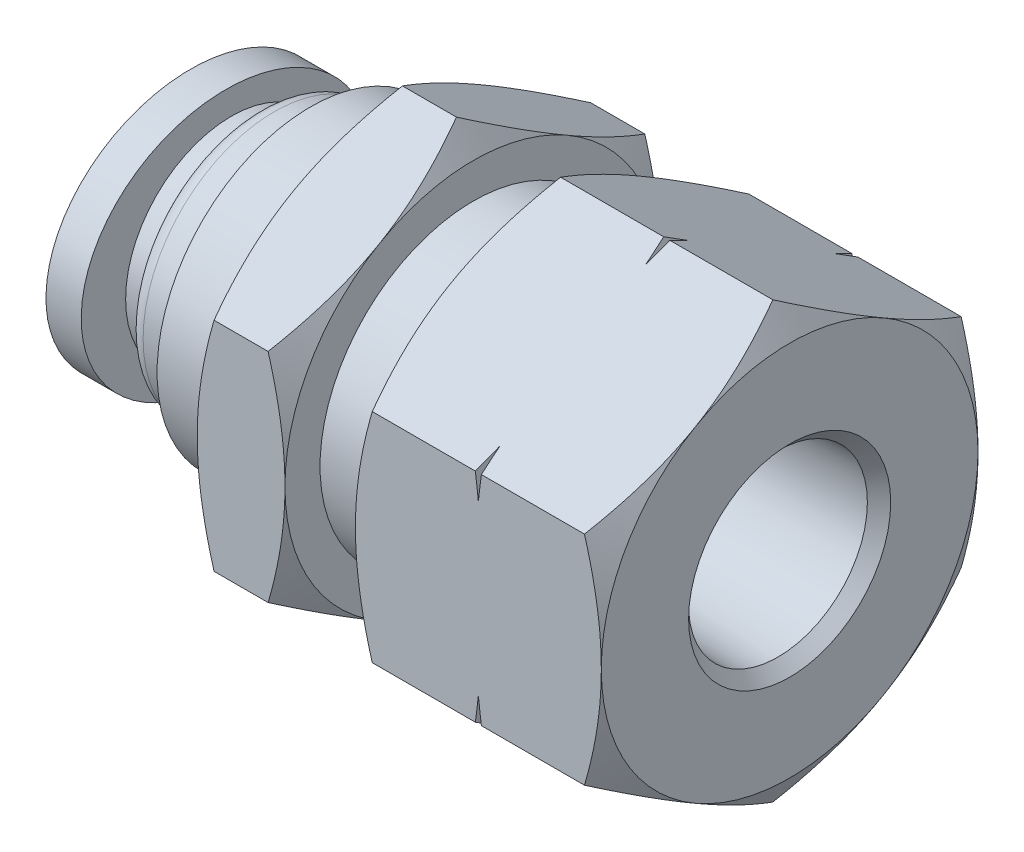
from build123d import *

# Parameters (mm, degrees)
BOSS_EXTRUDE1_DEPTH = 13.49375
CHAMFER1_SIZE2      = 0.508
CHAMFER1_SIZE       = 0.525425432
SKETCH3_RX          = 6.50875
SKETCH3_RY          = 5.6769
SKETCH3_R           = 3.3147
BOSS_EXTRUDE2_DEPTH = 1.5875


with BuildPart() as part:
    # Sketch1 → Boss-Extrude1 (new body, symmetric)
    with BuildSketch(Plane(origin=(0, 0, 0), x_dir=(0, 0, -1), z_dir=(1, 0, 0))):
        Polygon((0, 9.796017487), (-8.4836, 4.898008744), (-8.4836, -4.898008744), (0, -9.796017487), (8.4836, -4.898008744), (8.4836, 4.898008744), align=None)
    extrude(amount=BOSS_EXTRUDE1_DEPTH, both=True)

    # Sketch2 → Cut-Revolve1 (revolve, cut)
    with BuildSketch(Plane.XY):
        Polygon((13.49375, 9.796017487), (13.49375, 8.4836), (12.73602541, 9.796017487), align=None)
        Polygon((3.17707459, 9.796017487), (-1.51337459, 9.796017487), (-0.75565, 8.4836), (-0.75565, 6.90245), (2.41935, 6.90245), (2.41935, 8.4836), align=None)
        Polygon((7.82043181, 9.796017487), (7.95655, 9.288017487), (8.09266819, 9.796017487), align=None)
        with BuildLine():
            Line((-3.94762541, 9.796017487), (-4.70535, 8.4836))
            Line((-4.70535, 8.4836), (-4.70535, 6.90245))
            Line((-4.70535, 6.90245), (-8.09625, 6.90245))
            Line((-8.09625, 6.90245), (-8.09625, 5.9055))
            Line((-8.09625, 5.9055), (-9.72185, 5.9055))
            ThreePointArc((-9.72185, 5.9055), (-10.260665367, 5.682315367), (-10.48385, 5.1435))
            Line((-10.48385, 5.1435), (-10.48385, 4.7625))
            Line((-10.48385, 4.7625), (-11.65225, 4.7625))
            Line((-11.65225, 4.7625), (-11.65225, 3.81))
            Line((-11.65225, 3.81), (-13.49375, 3.81))
            Line((-13.49375, 3.81), (-13.49375, 9.796017487))
            Line((-13.49375, 9.796017487), (-3.94762541, 9.796017487))
        make_face()
        Polygon((13.49375, 4.043670494), (4.19735, 3.74015), (3.497110726, 2.5273), (2.25425, 2.5273), (2.25425, 3.81), (-5.87375, 3.81), (-5.87375, 3.3147), (-13.49375, 3.3147), (-13.49375, 0), (13.49375, 0), align=None)
    revolve(axis=Axis((13.49375, 0, 0), (-1, 0, 0)), mode=Mode.SUBTRACT)

    # Chamfer1
    chamfer1_edges = [part.edges().sort_by_distance(p)[0] for p in [
        (13.49375, -4.043670494, 0),
    ]]
    chamfer(chamfer1_edges, length=CHAMFER1_SIZE, length2=CHAMFER1_SIZE2)

    # Sketch3 → Boss-Extrude2 (add)
    with BuildSketch(Plane.ZY.offset(13.49375)):
        with Locations(Location((0, 0), (0, 0, 180))):
            Ellipse(SKETCH3_RX, SKETCH3_RY)
        Circle(SKETCH3_R, mode=Mode.SUBTRACT)
    extrude(amount=-BOSS_EXTRUDE2_DEPTH)


solid = part.part
